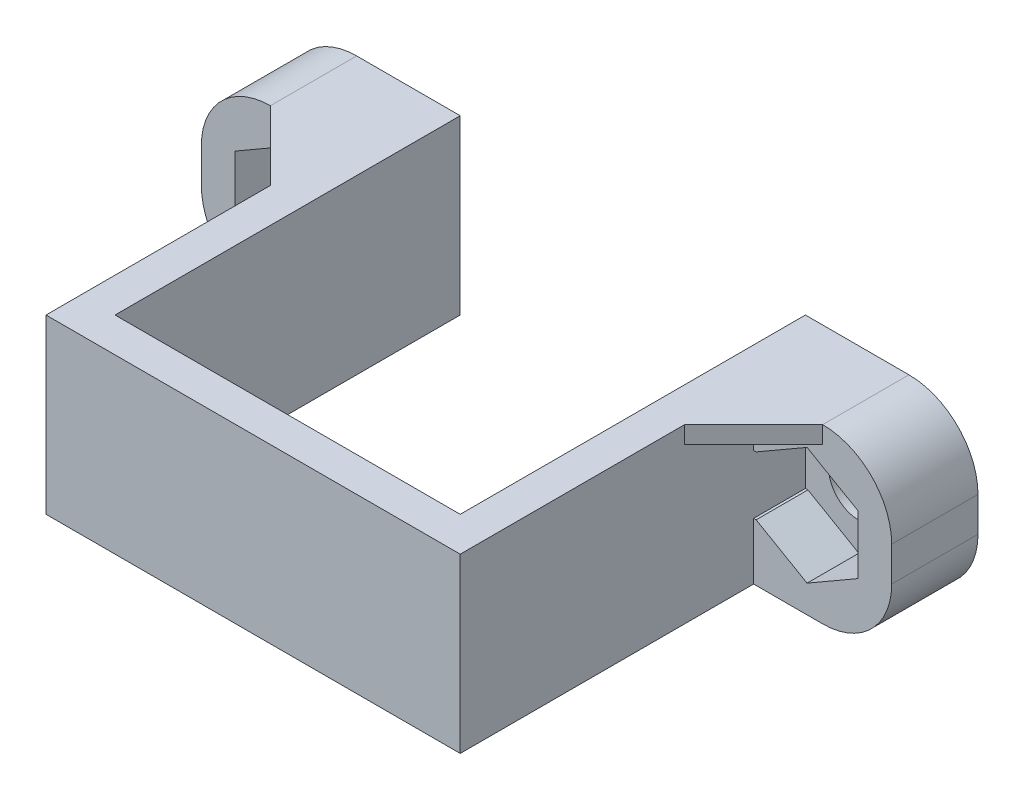
from build123d import *

# Parameters (mm, degrees)
EXTRUDE_1_DEPTH     = 10
FILLET_1_R          = 4
EXTRUDE_2_DEPTH     = 3
SKETCH_3_R          = 1.75
CUT_EXTRUDE_1_DEPTH = 3
EXTRUDE_3_DEPTH     = 1


with BuildPart() as part:
    # Эскиз1 → Бобышка-Вытянуть1 (new body)
    with BuildSketch(Plane(origin=(0, 0, 0), x_dir=(1, 0, 0), z_dir=(0, 1, 0))):
        Polygon((-10, 0), (10, 0), (10, 20), (20, 20), (20, 18), (12, 18), (12, -2), (-12, -2), (-12, 18), (-20, 18), (-20, 20), (-10, 20), align=None)
    extrude(amount=EXTRUDE_1_DEPTH)

    # Скругление1
    fillet_1_edges = [part.edges().sort_by_distance(p)[0] for p in [
        (20, 0, -19),
        (-20, 0, -19),
        (-20, 10, -19),
        (20, 10, -19),
    ]]
    fillet(fillet_1_edges, radius=FILLET_1_R)

    # Эскиз2 → Бобышка-Вытянуть2 (add)
    with BuildSketch(Plane.XY.offset(-18)):
        with BuildLine():
            Line((-12.145, 6.703183294), (-12, 6.703183294))
            Line((-12, 6.703183294), (-12, 10))
            Line((-12, 10), (-16, 10))
            ThreePointArc((-16, 10), (-18.828427125, 8.828427125), (-20, 6))
            Line((-20, 6), (-20, 4))
            ThreePointArc((-20, 4), (-18.828427125, 1.171572875), (-16, 0))
            Line((-16, 0), (-12, 0))
            Line((-12, 0), (-12, 3.296816706))
            Line((-12, 3.296816706), (-12.145, 3.296816706))
            Line((-12.145, 3.296816706), (-15.095, 1.593633412))
            Line((-15.095, 1.593633412), (-18.045, 3.296816706))
            Line((-18.045, 3.296816706), (-18.045, 6.703183294))
            Line((-18.045, 6.703183294), (-15.095, 8.406366588))
            Line((-15.095, 8.406366588), (-12.145, 6.703183294))
        make_face()
        with BuildLine():
            Line((20, 4), (20, 6))
            ThreePointArc((20, 6), (18.828427125, 8.828427125), (16, 10))
            Line((16, 10), (12, 10))
            Line((12, 10), (12, 6.703183294))
            Line((12, 6.703183294), (12.145, 6.703183294))
            Line((12.145, 6.703183294), (15.095, 8.406366588))
            Line((15.095, 8.406366588), (18.045, 6.703183294))
            Line((18.045, 6.703183294), (18.045, 3.296816706))
            Line((18.045, 3.296816706), (15.095, 1.593633412))
            Line((15.095, 1.593633412), (12.145, 3.296816706))
            Line((12.145, 3.296816706), (12, 3.296816706))
            Line((12, 3.296816706), (12, 0))
            Line((12, 0), (16, 0))
            ThreePointArc((16, 0), (18.828427125, 1.171572875), (20, 4))
        make_face()
    extrude(amount=EXTRUDE_2_DEPTH)

    # Эскиз3 → Вырез-Вытянуть1 (cut, through all)
    with BuildSketch(Plane.XY.offset(-18)):
        with Locations((-15.095, 5)):
            Circle(SKETCH_3_R)
        with Locations((15.095, 5)):
            Circle(SKETCH_3_R)
    extrude(amount=-CUT_EXTRUDE_1_DEPTH, mode=Mode.SUBTRACT)

    # Эскиз4 → Бобышка-Вытянуть3 (add)
    with BuildSketch(Plane(origin=(0, 10, 0), x_dir=(1, 0, 0), z_dir=(0, 1, 0))):
        Polygon((-16, 15), (-12, 11), (-12, 15), align=None)
        Polygon((12, 15), (16, 15), (12, 11), align=None)
    extrude(amount=-EXTRUDE_3_DEPTH)


solid = part.part
